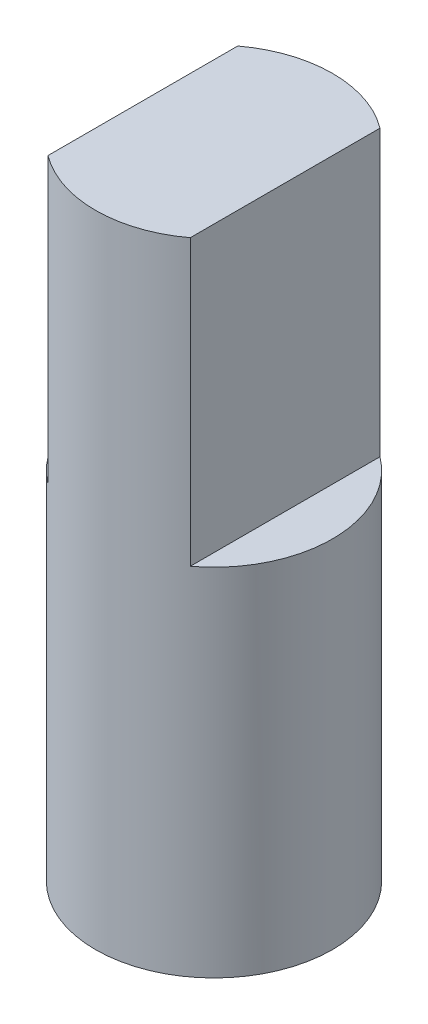
from build123d import *

# Parameters (mm, degrees)
CROQUIS1_R              = 14
CROQUIS1_W              = 14.155779923
CROQUIS1_H              = 14.6
SALIENTE_EXTRUIR1_DEPTH = 19
CROQUIS2_R              = 4.5
SALIENTE_EXTRUIR2_DEPTH = 1.5
CROQUIS3_R              = 2.5
SALIENTE_EXTRUIR3_DEPTH = 2.5
SALIENTE_EXTRUIR4_DEPTH = 6
CROQUIS5_W              = 18.5
CROQUIS5_H              = 1.5
CORTAR_EXTRUIR3_DEPTH   = 50
CROQUIS6_R              = 2.5
SALIENTE_EXTRUIR5_DEPTH = 5


with BuildPart() as part:
    # Croquis1 → Saliente-Extruir1 (new body)
    with BuildSketch(Plane(origin=(0, 0, 0), x_dir=(1, 0, 0), z_dir=(0, 1, 0))):
        Circle(CROQUIS1_R)
        with Locations((9.922110038, 0)):
            Rectangle(CROQUIS1_W, CROQUIS1_H)
    extrude(amount=SALIENTE_EXTRUIR1_DEPTH)

    # Croquis2 → Saliente-Extruir2 (add)
    with BuildSketch(Plane(origin=(0, 19, 0), x_dir=(1, 0, 0), z_dir=(0, 1, 0))):
        with Locations((-8, 0)):
            Circle(CROQUIS2_R)
    extrude(amount=SALIENTE_EXTRUIR2_DEPTH)

    # Croquis3 → Saliente-Extruir3 (add)
    with BuildSketch(Plane(origin=(0, 20.5, 0), x_dir=(1, 0, 0), z_dir=(0, 1, 0))):
        with Locations((-8, 0)):
            Circle(CROQUIS3_R)
    extrude(amount=SALIENTE_EXTRUIR3_DEPTH)

    # Croquis4 → Saliente-Extruir4 (add)
    with BuildSketch(Plane(origin=(0, 23, 0), x_dir=(1, 0, 0), z_dir=(0, 1, 0))):
        with BuildLine():
            Line((-9.5, 2), (-9.5, -2))
            ThreePointArc((-9.5, -2), (-8, -2.5), (-6.5, -2))
            Line((-6.5, -2), (-6.5, 2))
            ThreePointArc((-6.5, 2), (-8, 2.5), (-9.5, 2))
        make_face()
    extrude(amount=SALIENTE_EXTRUIR4_DEPTH)

    # Croquis5 → Cortar-Extruir3 (cut)
    with BuildSketch(Plane(origin=(17, 0, 0), x_dir=(0, 0, -1), z_dir=(1, 0, 0))):
        with Locations((-4.75, 19.75)):
            Rectangle(CROQUIS5_W, CROQUIS5_H)
        Polygon((4.5, 19), (-14, 19), (-14, 0), (14, 0), (14, 19), align=None)
    extrude(amount=-CORTAR_EXTRUIR3_DEPTH, mode=Mode.SUBTRACT)

    # Croquis6 → Saliente-Extruir5 (add)
    with BuildSketch(Plane.XZ.offset(-20.5)):
        with Locations((-8, 0)):
            Circle(CROQUIS6_R)
    extrude(amount=SALIENTE_EXTRUIR5_DEPTH)


solid = part.part
